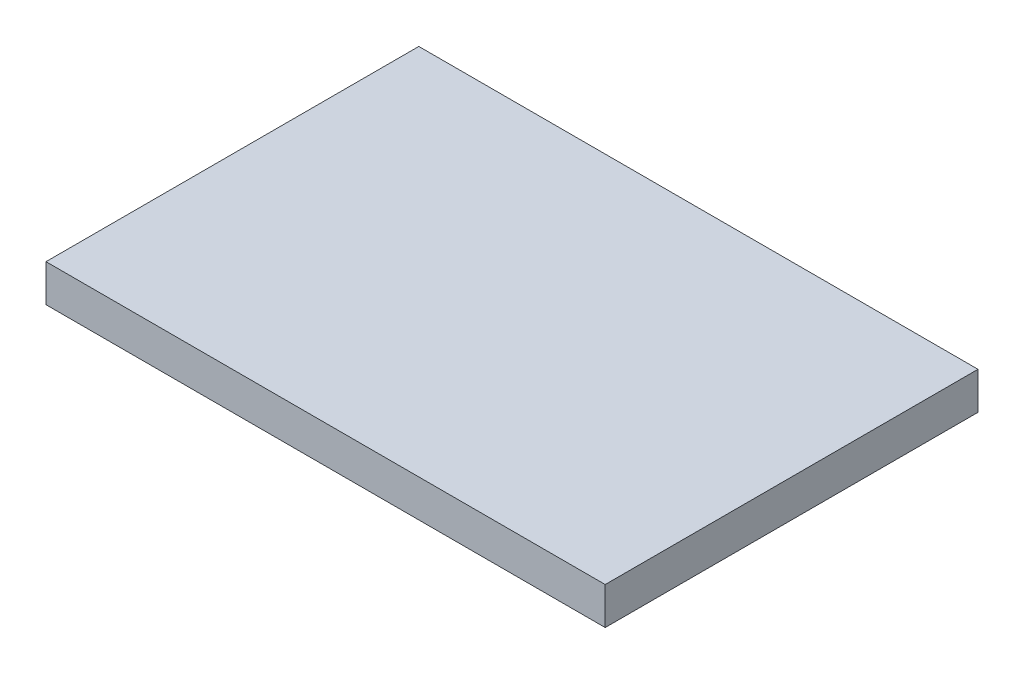
from build123d import *

# Parameters (mm, degrees)
SKETCH1_W           = 75
SKETCH1_H           = 50
BOSS_EXTRUDE1_DEPTH = 5


with BuildPart() as part:
    # Sketch1 → Boss-Extrude1 (new body)
    with BuildSketch(Plane(origin=(0, 0, 0), x_dir=(1, 0, 0), z_dir=(0, 1, 0))):
        with Locations((37.5, 25)):
            Rectangle(SKETCH1_W, SKETCH1_H)
    extrude(amount=BOSS_EXTRUDE1_DEPTH)


solid = part.part
